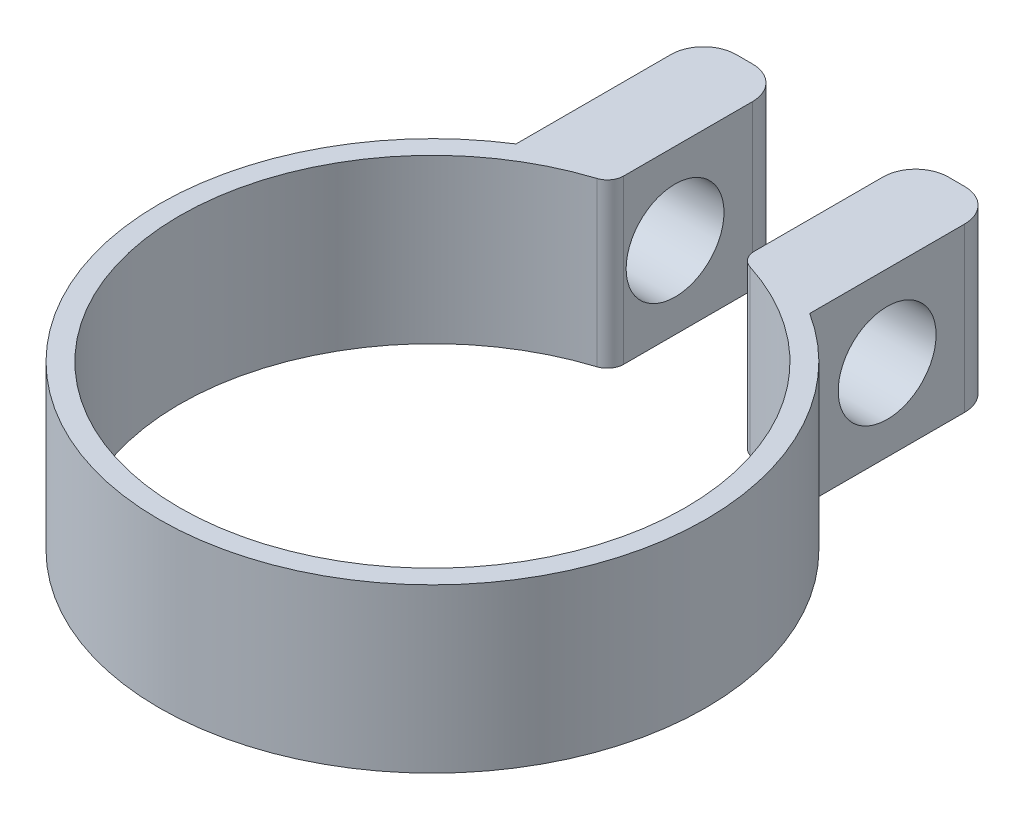
from build123d import *

# Parameters (mm, degrees)
SALIENTE_EXTRUIR1_DEPTH = 10
REDONDEO1_R             = 1
REDONDEO2_R             = 2
CROQUIS2_R              = 3
CORTAR_EXTRUIR1_DEPTH   = 26.75


with BuildPart() as part:
    # Croquis1 → Saliente-Extruir1 (new body)
    with BuildSketch(Plane(origin=(0, 0, 0), x_dir=(1, 0, 0), z_dir=(0, 1, 0))):
        with BuildLine():
            Line((-9, 14.126659195), (-9, 25.619429464))
            Line((-9, 25.619429464), (-4, 25.619429464))
            Line((-4, 25.619429464), (-4, 14.974979132))
            ThreePointArc((-4, 14.974979132), (0, -15.5), (4, 14.974979132))
            Line((4, 14.974979132), (4, 25.619429464))
            Line((4, 25.619429464), (9, 25.619429464))
            Line((9, 25.619429464), (9, 14.126659195))
            ThreePointArc((9, 14.126659195), (0, -16.75), (-9, 14.126659195))
        make_face()
    extrude(amount=SALIENTE_EXTRUIR1_DEPTH)

    # Redondeo1
    redondeo1_edges = [part.edges().sort_by_distance(p)[0] for p in [
        (-4, 5, -14.974979132),
        (4, 5, -14.974979132),
    ]]
    fillet(redondeo1_edges, radius=REDONDEO1_R)

    # Redondeo2
    redondeo2_edges = [part.edges().sort_by_distance(p)[0] for p in [
        (-9, 5, -25.619429464),
        (-4, 5, -25.619429464),
        (4, 5, -25.619429464),
        (9, 5, -25.619429464),
    ]]
    fillet(redondeo2_edges, radius=REDONDEO2_R)

    # Croquis2 → Cortar-Extruir1 (cut, through all)
    with BuildSketch(Plane(origin=(9, 0, 0), x_dir=(0, 0, -1), z_dir=(1, 0, 0))):
        with Locations((18.873044329, 5)):
            Circle(CROQUIS2_R)
    extrude(amount=-CORTAR_EXTRUIR1_DEPTH, mode=Mode.SUBTRACT)


solid = part.part
